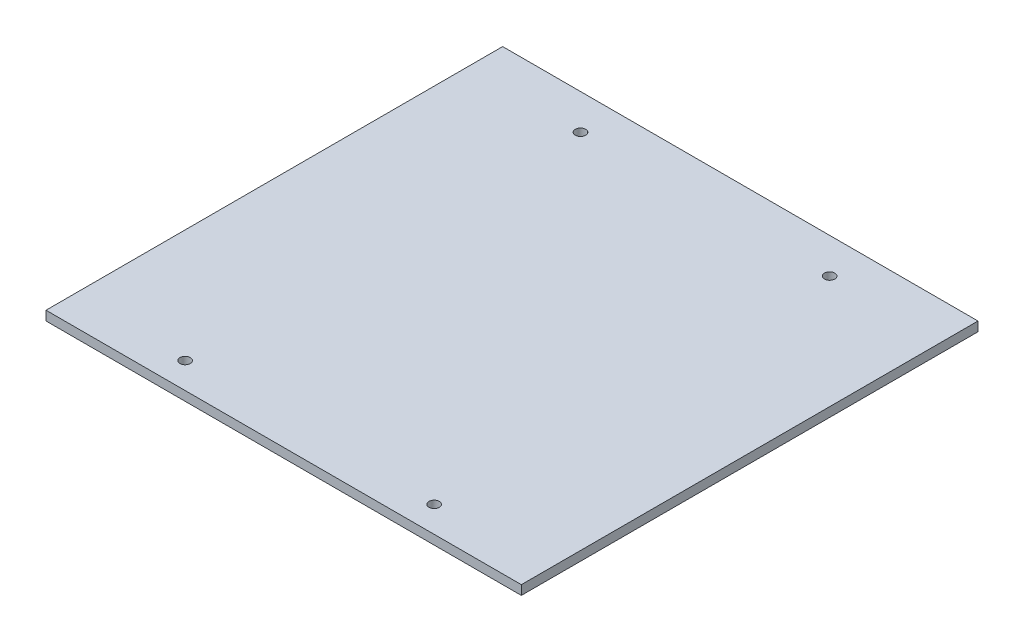
from build123d import *

# Parameters (mm, degrees)
SKETCH1_W           = 229
SKETCH1_H           = 220
BOSS_EXTRUDE1_DEPTH = 4.5
CUT_EXTRUDE1_REACH  = 6.5
SKETCH2_R           = 2.5


with BuildPart() as part:
    # Sketch1 → Boss-Extrude1 (new body)
    with BuildSketch(Plane(origin=(0, 0, 0), x_dir=(1, 0, 0), z_dir=(0, 1, 0))):
        Rectangle(SKETCH1_W, SKETCH1_H)
    extrude(amount=BOSS_EXTRUDE1_DEPTH)

    # Sketch2 → Cut-Extrude1 (cut, up to next)
    with BuildSketch(Plane.XZ, mode=Mode.PRIVATE) as cut_extrude1_sk1:
        with Locations((-60, 97.5)):
            Circle(SKETCH2_R)
    cut_extrude1_tool1 = extrude(cut_extrude1_sk1.sketch, amount=-CUT_EXTRUDE1_REACH, mode=Mode.PRIVATE) & part.part
    add(cut_extrude1_tool1.solids().sort_by_distance((-60, 0, 97.5))[0], mode=Mode.SUBTRACT)
    # Sketch2 → Cut-Extrude1 (cut, up to next)
    with BuildSketch(Plane.XZ, mode=Mode.PRIVATE) as cut_extrude1_sk2:
        with Locations((60, 97.5)):
            Circle(SKETCH2_R)
    cut_extrude1_tool2 = extrude(cut_extrude1_sk2.sketch, amount=-CUT_EXTRUDE1_REACH, mode=Mode.PRIVATE) & part.part
    add(cut_extrude1_tool2.solids().sort_by_distance((60, 0, 97.5))[0], mode=Mode.SUBTRACT)
    # Sketch2 → Cut-Extrude1 (cut, up to next)
    with BuildSketch(Plane.XZ, mode=Mode.PRIVATE) as cut_extrude1_sk3:
        with Locations((60, -93)):
            Circle(SKETCH2_R)
    cut_extrude1_tool3 = extrude(cut_extrude1_sk3.sketch, amount=-CUT_EXTRUDE1_REACH, mode=Mode.PRIVATE) & part.part
    add(cut_extrude1_tool3.solids().sort_by_distance((60, 0, -93))[0], mode=Mode.SUBTRACT)
    # Sketch2 → Cut-Extrude1 (cut, up to next)
    with BuildSketch(Plane.XZ, mode=Mode.PRIVATE) as cut_extrude1_sk4:
        with Locations((-60, -93)):
            Circle(SKETCH2_R)
    cut_extrude1_tool4 = extrude(cut_extrude1_sk4.sketch, amount=-CUT_EXTRUDE1_REACH, mode=Mode.PRIVATE) & part.part
    add(cut_extrude1_tool4.solids().sort_by_distance((-60, 0, -93))[0], mode=Mode.SUBTRACT)


solid = part.part
